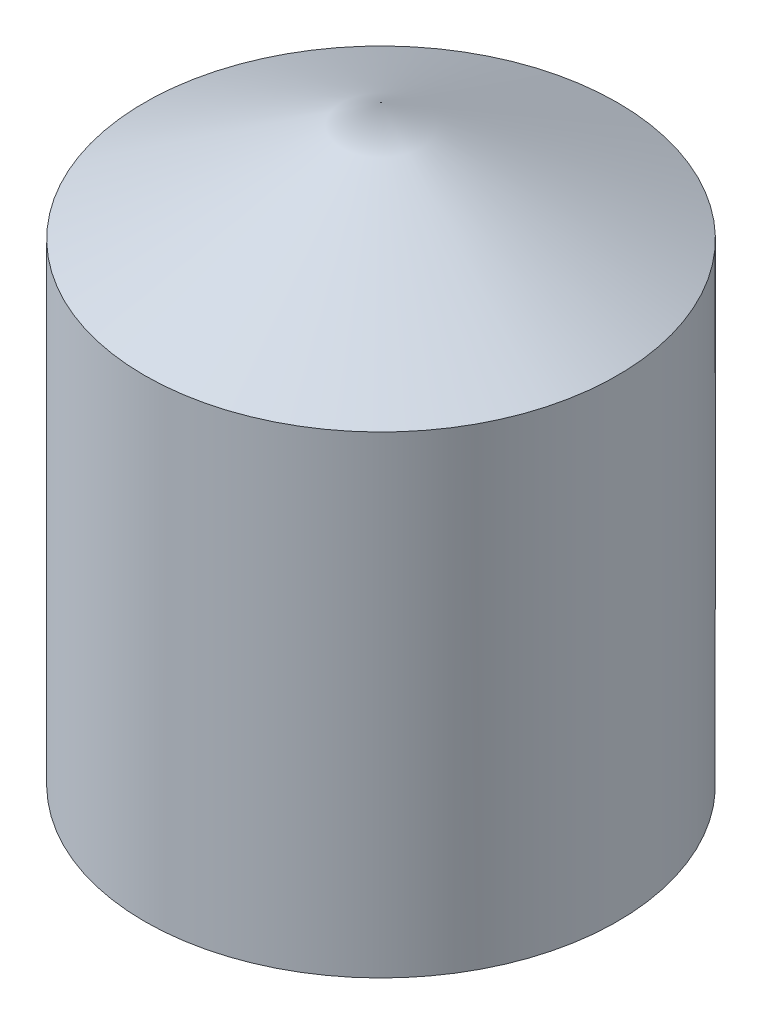
from build123d import *

# Parameters (mm, degrees)
SKETCH1_R           = 25.4
BOSS_EXTRUDE1_DEPTH = 50.8


with BuildPart() as part:
    # Sketch1 → Boss-Extrude1 (new body)
    with BuildSketch(Plane(origin=(0, 0, 0), x_dir=(1, 0, 0), z_dir=(0, 1, 0))):
        Circle(SKETCH1_R)
    extrude(amount=BOSS_EXTRUDE1_DEPTH)

    # Sketch2 → Revolve1 (revolve)
    with BuildSketch(Plane.XY):
        Polygon((0, 50.8), (0, 63.5), (25.4, 50.8), align=None)
    revolve(axis=Axis((0, 50.8, 0), (0, 1, 0)))


solid = part.part
